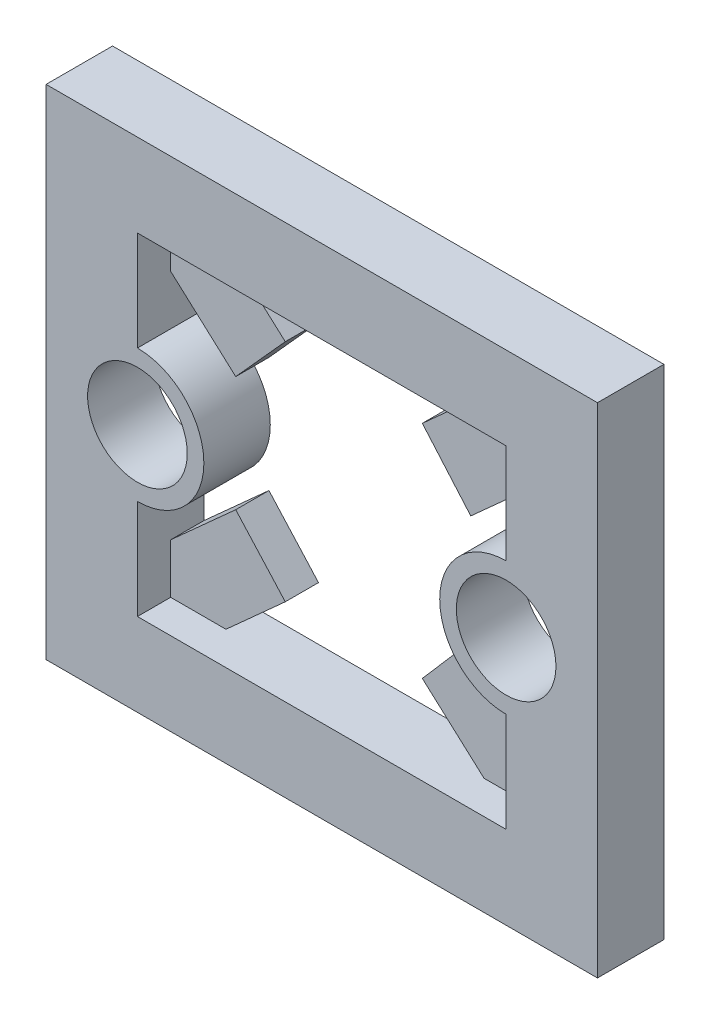
from build123d import *

# Parameters (mm, degrees)
SKETCH1_W           = 16.600054
SKETCH1_H           = 15
SKETCH1_R           = 1.5
BOSS_EXTRUDE1_DEPTH = 2
BOSS_EXTRUDE2_DEPTH = 1


with BuildPart() as part:
    # Sketch1 → Boss-Extrude1 (new body)
    with BuildSketch(Plane.XY):
        with Locations((12.458065, 13.09497)):
            Rectangle(SKETCH1_W, SKETCH1_H)
        with BuildLine():
            ThreePointArc((6.908038, 11.09497), (8.908038, 13.09497), (6.908038, 15.09497))
            Line((6.908038, 15.09497), (6.908038, 18.09497))
            Line((6.908038, 18.09497), (18.008092, 18.09497))
            Line((18.008092, 18.09497), (18.008092, 15.09497))
            ThreePointArc((18.008092, 15.09497), (16.008092, 13.09497), (18.008092, 11.09497))
            Line((18.008092, 11.09497), (18.008092, 8.09497))
            Line((18.008092, 8.09497), (6.908038, 8.09497))
            Line((6.908038, 8.09497), (6.908038, 11.09497))
        make_face(mode=Mode.SUBTRACT)
        with Locations((6.908038, 13.09497)):
            Circle(SKETCH1_R, mode=Mode.SUBTRACT)
        with Locations((18.008092, 13.09497)):
            Circle(SKETCH1_R, mode=Mode.SUBTRACT)
    extrude(amount=BOSS_EXTRUDE1_DEPTH)

    # Sketch1_25 → Boss-Extrude2 (add)
    with BuildSketch(Plane.XY):
        Polygon((6.908038, 18.09497), (6.908038, 16.59497), (8.866977953, 14.830167817), (10.358845842, 16.48614923), (8.5730461, 18.09497), align=None)
        Polygon((8.866977953, 11.359772183), (6.908038, 9.59497), (6.908038, 8.09497), (8.5730461, 8.09497), (10.358845842, 9.70379077), align=None)
        Polygon((18.008092, 18.09497), (16.3430839, 18.09497), (14.485103938, 16.421122321), (15.943445071, 14.73493677), (18.008092, 16.59497), align=None)
        Polygon((14.485103938, 9.768817679), (16.3430839, 8.09497), (18.008092, 8.09497), (18.008092, 9.59497), (15.943445071, 11.45500323), align=None)
    extrude(amount=BOSS_EXTRUDE2_DEPTH)


solid = part.part
